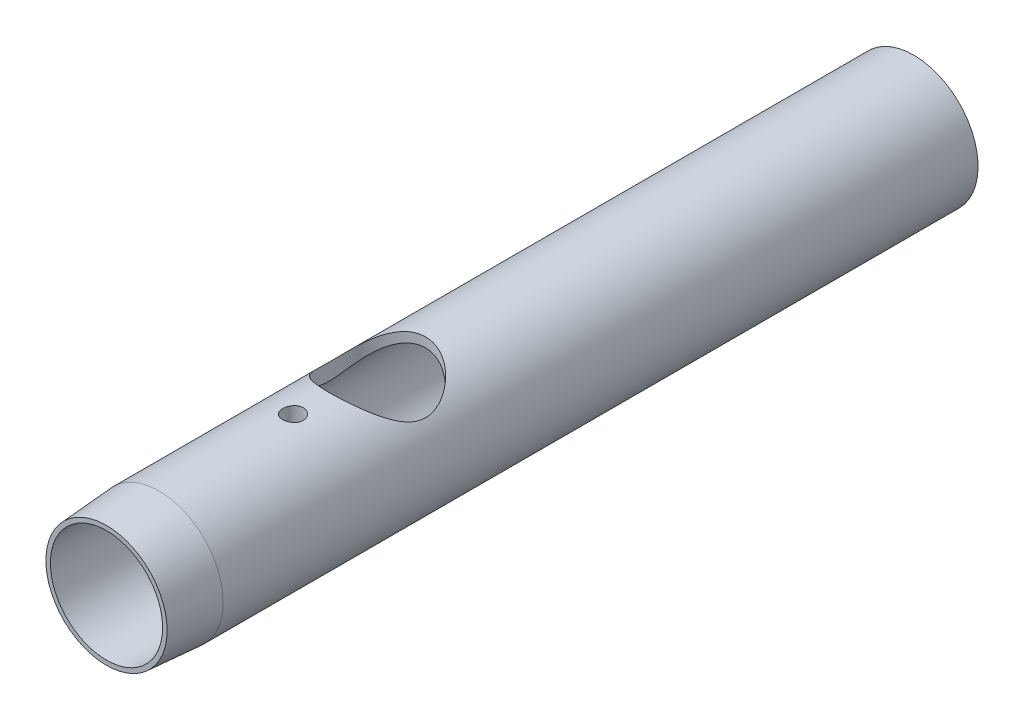
from build123d import *

# Parameters (mm, degrees)
SKETCH1_R           = 12.7
EXTRUDE1_DEPTH      = 159.512
SKETCH3_R           = 10.8204
CUT_EXTRUDE1_DEPTH  = 114.808
SKETCH4_R           = 9.017
CUT_EXTRUDE2_DEPTH  = 45.704
CHAMFER1_SIZE       = 1.778
CHAMFER2_SIZE       = 0.762
CHAMFER2_SIZE2      = 0.508
SKETCH5_R           = 9.5758
CUT_EXTRUDE3_DEPTH  = 29.21
SKETCH8_R           = 10.287
CUT_EXTRUDE5_DEPTH  = 25.273
SKETCH9_R           = 11.0871
CUT_EXTRUDE6_DEPTH  = 18.1864
CHAMFER3_SIZE       = 10.3632
CHAMFER3_SIZE2      = 0.7239
CUT_EXTRUDE7_DEPTH  = 7.62
SKETCH11_R          = 2.032
CUT_EXTRUDE11_DEPTH = 3.302
SKETCH15_R          = 1.7018
CUT_EXTRUDE12_DEPTH = 3.302
SKETCH16_R          = 9.525
CUT_EXTRUDE13_DEPTH = 12.7
SKETCH17_R          = 2.032
CUT_EXTRUDE14_DEPTH = 3.302
SKETCH18_R          = 1.7018
CUT_EXTRUDE15_DEPTH = 3.302


with BuildPart() as part:
    # Sketch1 → Extrude1 (new body)
    with BuildSketch(Plane.XY):
        Circle(SKETCH1_R)
    extrude(amount=EXTRUDE1_DEPTH)

    # Sketch3 → Cut-Extrude1 (cut)
    with BuildSketch(Plane(origin=(0, 0, 0), x_dir=(-1, 0, 0), z_dir=(0, 0, -1))):
        Circle(SKETCH3_R)
    extrude(amount=-CUT_EXTRUDE1_DEPTH, mode=Mode.SUBTRACT)

    # Sketch4 → Cut-Extrude2 (cut, through all)
    with BuildSketch(Plane(origin=(0, 0, 114.808), x_dir=(-1, 0, 0), z_dir=(0, 0, -1))):
        Circle(SKETCH4_R)
    extrude(amount=-CUT_EXTRUDE2_DEPTH, mode=Mode.SUBTRACT)

    # Chamfer1
    chamfer1_edges = [part.edges().sort_by_distance(p)[0] for p in [
        (9.017, 0, 114.808),
    ]]
    chamfer(chamfer1_edges, length=CHAMFER1_SIZE)

    # Chamfer2
    chamfer2_edges = [part.edges().sort_by_distance(p)[0] for p in [
        (9.017, 0, 116.586),
    ]]
    chamfer2_side = [part.faces().sort_by_distance(p)[0] for p in [
        (9.906, 0, 115.697),
    ]]
    chamfer(chamfer2_edges, length=CHAMFER2_SIZE, length2=CHAMFER2_SIZE2, reference=chamfer2_side[0])

    # Sketch5 → Cut-Extrude3 (cut)
    with BuildSketch(Plane.XY.offset(159.512)):
        Circle(SKETCH5_R)
    extrude(amount=-CUT_EXTRUDE3_DEPTH, mode=Mode.SUBTRACT)

    # Sketch8 → Cut-Extrude5 (cut)
    with BuildSketch(Plane.XY.offset(159.512)):
        Circle(SKETCH8_R)
    extrude(amount=-CUT_EXTRUDE5_DEPTH, mode=Mode.SUBTRACT)

    # Sketch9 → Cut-Extrude6 (cut)
    with BuildSketch(Plane.XY.offset(159.512)):
        Circle(SKETCH9_R)
    extrude(amount=-CUT_EXTRUDE6_DEPTH, mode=Mode.SUBTRACT)

    # Chamfer3
    chamfer3_edges = [part.edges().sort_by_distance(p)[0] for p in [
        (-12.7, 0, 159.512),
    ]]
    chamfer3_side = [part.faces().sort_by_distance(p)[0] for p in [
        (-12.7, 0, 79.756),
    ]]
    chamfer(chamfer3_edges, length=CHAMFER3_SIZE, length2=CHAMFER3_SIZE2, reference=chamfer3_side[0])

    # Sketch10 → Cut-Extrude7 (cut)
    with BuildSketch(Plane(origin=(0, -12.7, 0), x_dir=(-1, 0, 0), z_dir=(0, 1, 0))):
        with BuildLine():
            Line((2.3114, 0), (2.3114, 72.0725))
            ThreePointArc((2.3114, 72.0725), (2.776367985, 73.195032015), (3.8989, 73.66))
            Line((3.8989, 73.66), (5.4991, 73.66))
            ThreePointArc((5.4991, 73.66), (6.621632015, 74.124967985), (7.0866, 75.2475))
            Line((7.0866, 75.2475), (7.0866, 107.6325))
            ThreePointArc((7.0866, 107.6325), (6.621632015, 108.755032015), (5.4991, 109.22))
            Line((5.4991, 109.22), (3.3401, 109.22))
            ThreePointArc((3.3401, 109.22), (2.217567985, 108.755032015), (1.7526, 107.6325))
            Line((1.7526, 107.6325), (1.7526, 98.1075))
            ThreePointArc((1.7526, 98.1075), (1.287632015, 96.984967985), (0.1651, 96.52))
            Line((0.1651, 96.52), (-0.7239, 96.52))
            ThreePointArc((-0.7239, 96.52), (-1.846432015, 96.055032015), (-2.3114, 94.9325))
            Line((-2.3114, 94.9325), (-2.3114, 0))
            Line((-2.3114, 0), (2.3114, 0))
        make_face()
    extrude(amount=CUT_EXTRUDE7_DEPTH, mode=Mode.SUBTRACT)

    # Sketch11 → Cut-Extrude11 (cut)
    with BuildSketch(Plane(origin=(0, -12.7, 0), x_dir=(-1, 0, 0), z_dir=(0, 1, 0))):
        with Locations(Location((0, 126.619, 0), (0, 0, 270))):  # turned: the seam where the file's is
            Circle(SKETCH11_R)
    extrude(amount=CUT_EXTRUDE11_DEPTH, mode=Mode.SUBTRACT)

    # Sketch15 → Cut-Extrude12 (cut)
    with BuildSketch(Plane.XZ.offset(9.398)):
        with Locations(Location((0, 126.619, 0), (0, 0, 270))):  # turned: the seam where the file's is
            Circle(SKETCH15_R)
    extrude(amount=-CUT_EXTRUDE12_DEPTH, mode=Mode.SUBTRACT)

    # Sketch16 → Cut-Extrude13 (cut)
    with BuildSketch(Plane(origin=(0, 12.7, 0), x_dir=(-1, 0, 0), z_dir=(0, 1, 0))):
        with Locations(Location((0, 105.9688, 0), (0, 0, 90))):  # turned: the seam where the file's is
            Circle(SKETCH16_R)
    extrude(amount=-CUT_EXTRUDE13_DEPTH, mode=Mode.SUBTRACT)

    # Sketch17 → Cut-Extrude14 (cut)
    with BuildSketch(Plane(origin=(0, 12.7, 0), x_dir=(-1, 0, 0), z_dir=(0, 1, 0))):
        with Locations(Location((0, 122.682, 0), (0, 0, 90))):  # turned: the seam where the file's is
            Circle(SKETCH17_R)
    extrude(amount=-CUT_EXTRUDE14_DEPTH, mode=Mode.SUBTRACT)

    # Sketch18 → Cut-Extrude15 (cut)
    with BuildSketch(Plane(origin=(0, 9.398, 0), x_dir=(-1, 0, 0), z_dir=(0, 1, 0))):
        with Locations(Location((0, 122.682, 0), (0, 0, 90))):  # turned: the seam where the file's is
            Circle(SKETCH18_R)
    extrude(amount=-CUT_EXTRUDE15_DEPTH, mode=Mode.SUBTRACT)


solid = part.part
